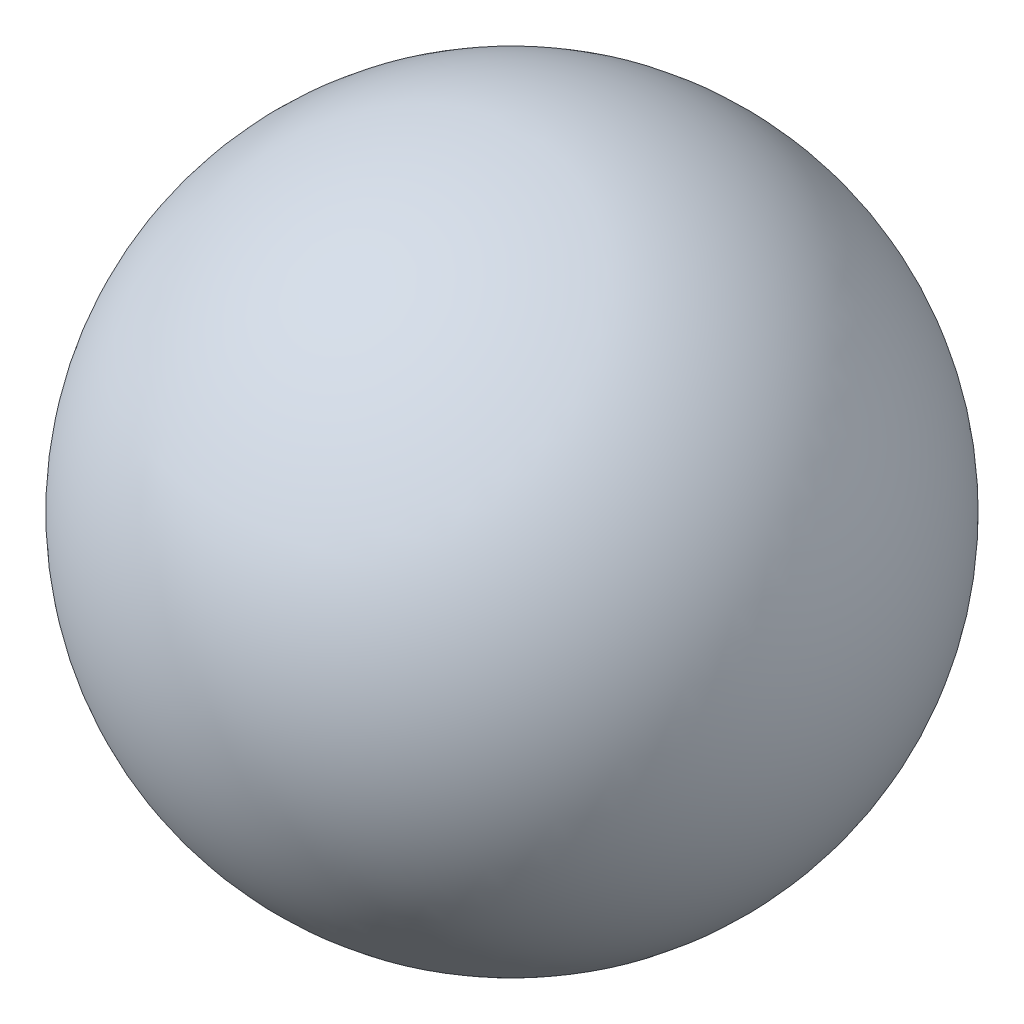
from build123d import *


with BuildPart() as part:
    # Skizze1 → Shpere (revolve)
    with BuildSketch(Plane.XY):
        with BuildLine():
            Line((0, 2.5), (0, -2.5))
            ThreePointArc((0, -2.5), (-2.5, 0), (0, 2.5))
        make_face()
    revolve(axis=Axis((0, 0, 0), (0, 1, 0)))


solid = part.part
